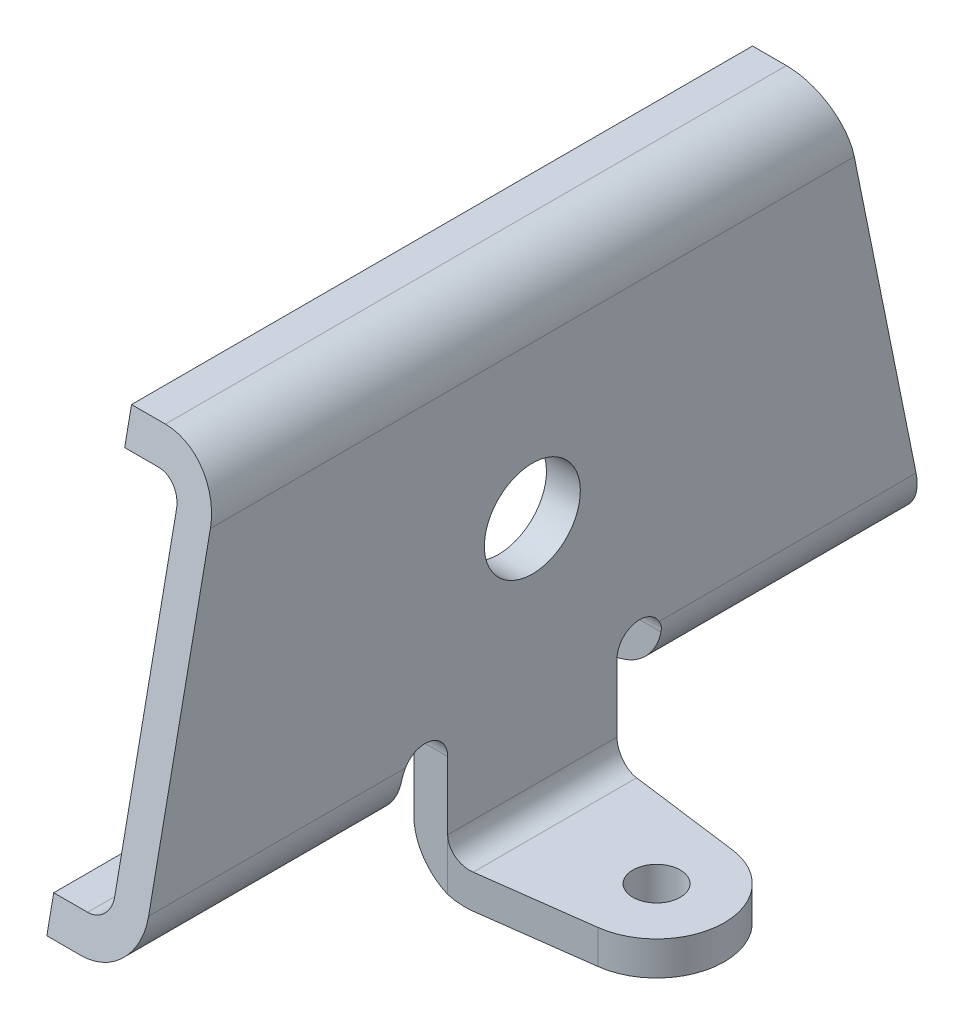
from build123d import *

# Parameters (mm, degrees)
EXTRUSION1_DEPTH         = 35
ENL_V_MAT_EXTRU_1_DEPTH  = 45.036916332
ESQUISSE8_W              = 15
ESQUISSE8_H              = 3
ENL_V_MAT_EXTRU_8_DEPTH  = 44.591857038
ESQUISSE9_W              = 23.50235156
ESQUISSE9_H              = 7
ENL_V_MAT_EXTRU_9_DEPTH  = 44.591857038
ESQUISSE11_R             = 2.1
EXTRUSION2_DEPTH         = 3
ESQUISSE12_R             = 4.25
ENL_V_MAT_EXTRU_10_DEPTH = 48.699580711
CONG_3_R                 = 2
CONG_4_R                 = 5
ENL_V_MAT_EXTRU_11_DEPTH = 47.521500481


with BuildPart() as part:
    # Esquisse1 → Extrusion1 (new, symmetric)
    with BuildSketch(Plane.XY):
        Polygon((-8, 18.5), (0, 18.5), (0, -25.5), (-3, -25.5), (-3, -18.5), (-8, -18.5), (-8, -15.5), (-3, -15.5), (-3, 15.5), (-8, 15.5), align=None)
    extrude(amount=EXTRUSION1_DEPTH, both=True)

    # Esquisse2 → Enlèv. mat.-Extru.1 (cut, through all)
    with BuildSketch(Plane.ZY.offset(8)):
        with BuildLine():
            Line((-11.49764844, -25.5), (-11.49764844, -14.49882422))
            ThreePointArc((-11.49764844, -14.49882422), (-9.49882422, -12.5), (-7.5, -14.49882422))
            Line((-7.5, -14.49882422), (-7.5, -25.5))
            Line((-7.5, -25.5), (-11.49764844, -25.5))
        make_face()
        with BuildLine():
            Line((7.5, -25.5), (7.5, -14.49882422))
            ThreePointArc((7.5, -14.49882422), (9.49882422, -12.5), (11.49764844, -14.49882422))
            Line((11.49764844, -14.49882422), (11.49764844, -25.5))
            Line((11.49764844, -25.5), (7.5, -25.5))
        make_face()
    extrude(amount=-ENL_V_MAT_EXTRU_1_DEPTH, mode=Mode.SUBTRACT)

    # Esquisse8 → Enlèv. mat.-Extru.8 (cut, through all)
    with BuildSketch(Plane.ZY.offset(3)):
        with Locations((0, -17)):
            Rectangle(ESQUISSE8_W, ESQUISSE8_H)
    extrude(amount=ENL_V_MAT_EXTRU_8_DEPTH, mode=Mode.SUBTRACT)

    # Esquisse9 → Enlèv. mat.-Extru.9 (cut, through all)
    with BuildSketch(Plane.ZY.offset(3)):
        with Locations((-23.24882422, -22)):
            Rectangle(ESQUISSE9_W, ESQUISSE9_H)
        with Locations((23.24882422, -22)):
            Rectangle(ESQUISSE9_W, ESQUISSE9_H)
    extrude(amount=-ENL_V_MAT_EXTRU_9_DEPTH, mode=Mode.SUBTRACT)

    # Esquisse11 → Extrusion2 (add)
    with BuildSketch(Plane.XZ.offset(25.5)):
        with BuildLine():
            Line((0, 7.5), (11.783181352, 5.948665982))
            ThreePointArc((11.783181352, 5.948665982), (17, 0), (11.783181352, -5.948665982))
            Line((11.783181352, -5.948665982), (0, -7.5))
            Line((0, -7.5), (0, 7.5))
        make_face()
        with Locations(Location((11, 0, 0), (0, 0, 270))):
            Circle(ESQUISSE11_R, mode=Mode.SUBTRACT)
    extrude(amount=-EXTRUSION2_DEPTH)

    # Esquisse12 → Enlèv. mat.-Extru.10 (cut, through all)
    with BuildSketch(Plane.ZY.offset(3)):
        with Locations(Location((0, 0, 0), (0, 0, 270))):
            Circle(ESQUISSE12_R)
    extrude(amount=-ENL_V_MAT_EXTRU_10_DEPTH, mode=Mode.SUBTRACT)

    # Congé3
    cong_3_edges = [part.edges().sort_by_distance(p)[0] for p in [
        (0, -22.5, 0),
        (-3, -15.5, 23.24882422),
        (-3, 15.5, 0),
        (-3, -15.5, -23.24882422),
    ]]
    fillet(cong_3_edges, radius=CONG_3_R)

    # Congé4
    cong_4_edges = [part.edges().sort_by_distance(p)[0] for p in [
        (0, -18.5, -23.24882422),
        (0, -18.5, 23.24882422),
        (0, 18.5, 0),
        (-3, -25.5, 0),
    ]]
    fillet(cong_4_edges, radius=CONG_4_R)

    # Esquisse13 → Enlèv. mat.-Extru.11 (cut, through all)
    with BuildSketch(Plane(origin=(0, 0, 0), x_dir=(0, 0, -1), z_dir=(1, 0, 0))):
        Polygon((-35, 18.5), (-35, -18.5), (-27.5, 18.5), align=None)
        Polygon((35, 18.5), (35, -18.5), (27.5, 18.5), align=None)
    extrude(amount=-ENL_V_MAT_EXTRU_11_DEPTH, mode=Mode.SUBTRACT)


solid = part.part
